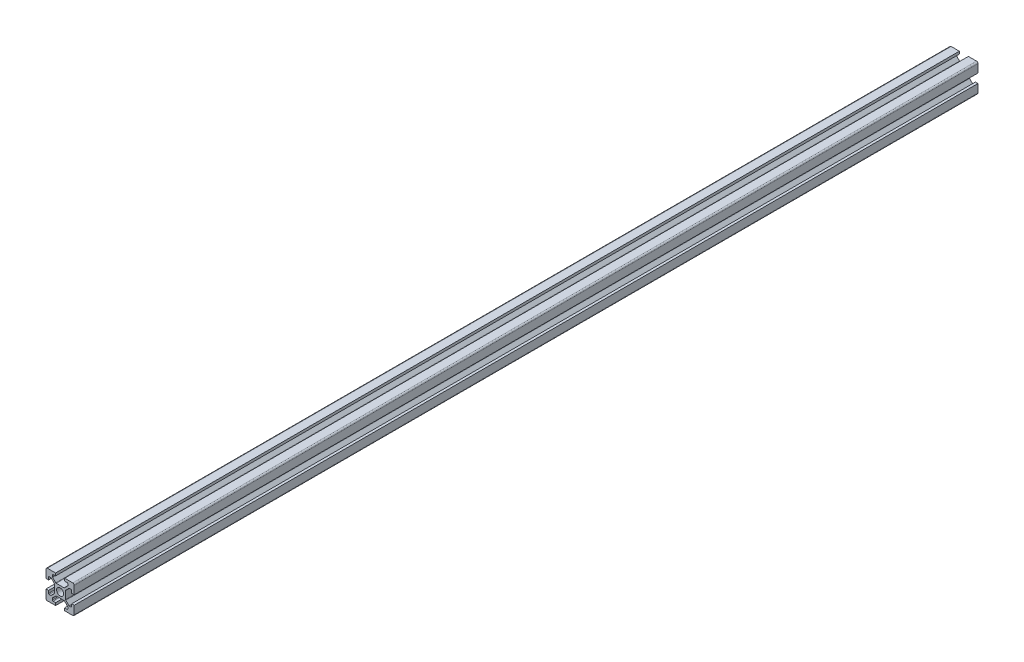
from build123d import *

# Parameters (mm, degrees)
SKETCH1_R           = 2.5
BOSS_EXTRUDE1_DEPTH = 300
FILLET1_R           = 1
FILLET2_R           = 0.5
FILLET3_R           = 0.5
FILLET4_R           = 0.5
FILLET5_R           = 0.5
BOSS_EXTRUDE2_DEPTH = 340


with BuildPart() as part:
    # Sketch1 → Boss-Extrude1 (new body)
    with BuildSketch(Plane.XY):
        Polygon((13.2, 0), (13.2, 1.8), (15.45, 1.8), (15.45, 3.6), (12.95, 6.1), (7.05, 6.1), (4.55, 3.6), (4.55, 1.8), (6.8, 1.8), (6.8, 0), (0, 0), (0, 6.8), (1.8, 6.8), (1.8, 4.55), (3.6, 4.55), (6.1, 7.05), (6.1, 12.95), (3.6, 15.45), (1.8, 15.45), (1.8, 13.2), (0, 13.2), (0, 20), (6.8, 20), (6.8, 18.2), (4.55, 18.2), (4.55, 16.4), (7.05, 13.9), (12.95, 13.9), (15.45, 16.4), (15.45, 18.2), (13.2, 18.2), (13.2, 20), (20, 20), (20, 13.2), (18.2, 13.2), (18.2, 15.45), (16.4, 15.45), (13.9, 12.95), (13.9, 7.05), (16.4, 4.55), (18.2, 4.55), (18.2, 6.8), (20, 6.8), (20, 0), align=None)
        with Locations((10, 10)):
            Circle(SKETCH1_R, mode=Mode.SUBTRACT)
    extrude(amount=BOSS_EXTRUDE1_DEPTH)

    # Fillet1
    fillet1_edges = [part.edges().sort_by_distance(p)[0] for p in [
        (0, 0, 150),
        (0, 20, 150),
        (20, 20, 150),
        (20, 0, 150),
    ]]
    fillet(fillet1_edges, radius=FILLET1_R)

    # Fillet2
    fillet2_edges = [part.edges().sort_by_distance(p)[0] for p in [
        (4.55, 18.2, 150),
        (4.55, 16.4, 150),
        (7.05, 13.9, 150),
        (12.95, 13.9, 150),
        (15.45, 16.4, 150),
        (15.45, 18.2, 150),
    ]]
    fillet(fillet2_edges, radius=FILLET2_R)

    # Fillet3
    fillet3_edges = [part.edges().sort_by_distance(p)[0] for p in [
        (18.2, 15.45, 150),
        (16.4, 15.45, 150),
        (13.9, 12.95, 150),
        (13.9, 7.05, 150),
        (16.4, 4.55, 150),
        (18.2, 4.55, 150),
    ]]
    fillet(fillet3_edges, radius=FILLET3_R)

    # Fillet4
    fillet4_edges = [part.edges().sort_by_distance(p)[0] for p in [
        (1.8, 4.55, 150),
        (3.6, 4.55, 150),
        (6.1, 7.05, 150),
        (6.1, 12.95, 150),
        (3.6, 15.45, 150),
        (1.8, 15.45, 150),
    ]]
    fillet(fillet4_edges, radius=FILLET4_R)

    # Fillet5
    fillet5_edges = [part.edges().sort_by_distance(p)[0] for p in [
        (15.45, 1.8, 150),
        (15.45, 3.6, 150),
        (12.95, 6.1, 150),
        (7.05, 6.1, 150),
        (4.55, 3.6, 150),
        (4.55, 1.8, 150),
    ]]
    fillet(fillet5_edges, radius=FILLET5_R)

    # Sketch4 → Boss-Extrude2 (add)
    with BuildSketch(Plane(origin=(0, 0, 0), x_dir=(-1, 0, 0), z_dir=(0, 0, -1))):
        with BuildLine():
            Line((-13.2, 20), (-19, 20))
            ThreePointArc((-19, 20), (-19.707106781, 19.707106781), (-20, 19))
            Line((-20, 19), (-20, 13.2))
            Line((-20, 13.2), (-18.2, 13.2))
            Line((-18.2, 13.2), (-18.2, 14.95))
            ThreePointArc((-18.2, 14.95), (-18.053553391, 15.303553391), (-17.7, 15.45))
            Line((-17.7, 15.45), (-16.607106781, 15.45))
            ThreePointArc((-16.607106781, 15.45), (-16.415765065, 15.411939766), (-16.253553391, 15.303553391))
            Line((-16.253553391, 15.303553391), (-14.046446609, 13.096446609))
            ThreePointArc((-14.046446609, 13.096446609), (-13.938060234, 12.934234935), (-13.9, 12.742893219))
            Line((-13.9, 12.742893219), (-13.9, 7.257106781))
            ThreePointArc((-13.9, 7.257106781), (-13.938060234, 7.065765065), (-14.046446609, 6.903553391))
            Line((-14.046446609, 6.903553391), (-16.253553391, 4.696446609))
            ThreePointArc((-16.253553391, 4.696446609), (-16.415765065, 4.588060234), (-16.607106781, 4.55))
            Line((-16.607106781, 4.55), (-17.7, 4.55))
            ThreePointArc((-17.7, 4.55), (-18.053553391, 4.696446609), (-18.2, 5.05))
            Line((-18.2, 5.05), (-18.2, 6.8))
            Line((-18.2, 6.8), (-20, 6.8))
            Line((-20, 6.8), (-20, 1))
            ThreePointArc((-20, 1), (-19.707106781, 0.292893219), (-19, 0))
            Line((-19, 0), (-13.2, 0))
            Line((-13.2, 0), (-13.2, 1.8))
            Line((-13.2, 1.8), (-14.95, 1.8))
            ThreePointArc((-14.95, 1.8), (-15.303553391, 1.946446609), (-15.45, 2.3))
            Line((-15.45, 2.3), (-15.45, 3.392893219))
            ThreePointArc((-15.45, 3.392893219), (-15.411939766, 3.584234935), (-15.303553391, 3.746446609))
            Line((-15.303553391, 3.746446609), (-13.096446609, 5.953553391))
            ThreePointArc((-13.096446609, 5.953553391), (-12.934234935, 6.061939766), (-12.742893219, 6.1))
            Line((-12.742893219, 6.1), (-7.257106781, 6.1))
            ThreePointArc((-7.257106781, 6.1), (-7.065765065, 6.061939766), (-6.903553391, 5.953553391))
            Line((-6.903553391, 5.953553391), (-4.696446609, 3.746446609))
            ThreePointArc((-4.696446609, 3.746446609), (-4.588060234, 3.584234935), (-4.55, 3.392893219))
            Line((-4.55, 3.392893219), (-4.55, 2.3))
            ThreePointArc((-4.55, 2.3), (-4.696446609, 1.946446609), (-5.05, 1.8))
            Line((-5.05, 1.8), (-6.8, 1.8))
            Line((-6.8, 1.8), (-6.8, 0))
            Line((-6.8, 0), (-1, 0))
            ThreePointArc((-1, 0), (-0.292893219, 0.292893219), (0, 1))
            Line((0, 1), (0, 6.8))
            Line((0, 6.8), (-1.8, 6.8))
            Line((-1.8, 6.8), (-1.8, 5.05))
            ThreePointArc((-1.8, 5.05), (-1.946446609, 4.696446609), (-2.3, 4.55))
            Line((-2.3, 4.55), (-3.392893219, 4.55))
            ThreePointArc((-3.392893219, 4.55), (-3.584234935, 4.588060234), (-3.746446609, 4.696446609))
            Line((-3.746446609, 4.696446609), (-5.953553391, 6.903553391))
            ThreePointArc((-5.953553391, 6.903553391), (-6.061939766, 7.065765065), (-6.1, 7.257106781))
            Line((-6.1, 7.257106781), (-6.1, 12.742893219))
            ThreePointArc((-6.1, 12.742893219), (-6.061939766, 12.934234935), (-5.953553391, 13.096446609))
            Line((-5.953553391, 13.096446609), (-3.746446609, 15.303553391))
            ThreePointArc((-3.746446609, 15.303553391), (-3.584234935, 15.411939766), (-3.392893219, 15.45))
            Line((-3.392893219, 15.45), (-2.3, 15.45))
            ThreePointArc((-2.3, 15.45), (-1.946446609, 15.303553391), (-1.8, 14.95))
            Line((-1.8, 14.95), (-1.8, 13.2))
            Line((-1.8, 13.2), (0, 13.2))
            Line((0, 13.2), (0, 19))
            ThreePointArc((0, 19), (-0.292893219, 19.707106781), (-1, 20))
            Line((-1, 20), (-6.8, 20))
            Line((-6.8, 20), (-6.8, 18.2))
            Line((-6.8, 18.2), (-5.05, 18.2))
            ThreePointArc((-5.05, 18.2), (-4.696446609, 18.053553391), (-4.55, 17.7))
            Line((-4.55, 17.7), (-4.55, 16.607106781))
            ThreePointArc((-4.55, 16.607106781), (-4.588060234, 16.415765065), (-4.696446609, 16.253553391))
            Line((-4.696446609, 16.253553391), (-6.903553391, 14.046446609))
            ThreePointArc((-6.903553391, 14.046446609), (-7.065765065, 13.938060234), (-7.257106781, 13.9))
            Line((-7.257106781, 13.9), (-12.742893219, 13.9))
            ThreePointArc((-12.742893219, 13.9), (-12.934234935, 13.938060234), (-13.096446609, 14.046446609))
            Line((-13.096446609, 14.046446609), (-15.303553391, 16.253553391))
            ThreePointArc((-15.303553391, 16.253553391), (-15.411939766, 16.415765065), (-15.45, 16.607106781))
            Line((-15.45, 16.607106781), (-15.45, 17.7))
            ThreePointArc((-15.45, 17.7), (-15.303553391, 18.053553391), (-14.95, 18.2))
            Line((-14.95, 18.2), (-13.2, 18.2))
            Line((-13.2, 18.2), (-13.2, 20))
        make_face()
    extrude(amount=BOSS_EXTRUDE2_DEPTH)


solid = part.part
